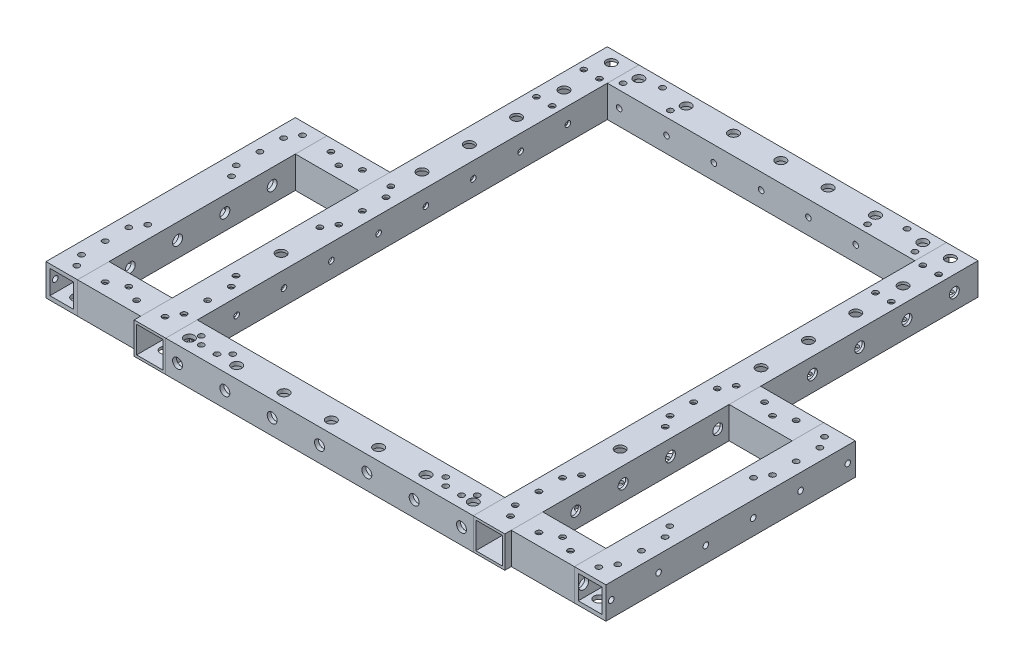
from build123d import *

# Parameters (mm, degrees)
BOSS_EXTRUDE1_DEPTH        = 105.6
BOSS_EXTRUDE1_DEPTH_BACK   = 275.4
SKETCH1_W                  = 25.4
SKETCH1_H                  = 25.4
SKETCH1_W_2                = 21.4
SKETCH1_H_2                = 21.4
BOSS_EXTRUDE1_2_DEPTH      = 105.6
BOSS_EXTRUDE1_2_DEPTH_BACK = 275.4
SKETCH10_W                 = 25.4
SKETCH10_H                 = 25.4
SKETCH10_W_2               = 19.05
SKETCH10_H_2               = 19.05
BOSS_EXTRUDE4_DEPTH        = 123.83
SKETCH5_W                  = 25.4
SKETCH5_H                  = 25.4
SKETCH5_W_2                = 21.4
SKETCH5_H_2                = 21.4
BOSS_EXTRUDE3_DEPTH        = 50.795
BOSS_EXTRUDE3_2_DEPTH      = 50.795
SKETCH11_W                 = 25.4
SKETCH11_H                 = 25.4
SKETCH11_W_2               = 19.05
SKETCH11_H_2               = 19.05
BOSS_EXTRUDE5_DEPTH        = 100.4
SKETCH12_R                 = 2.25
CUT_EXTRUDE1_DEPTH         = 10
SKETCH13_R                 = 4
CUT_EXTRUDE2_DEPTH         = 10
SKETCH14_R                 = 2.25
CUT_EXTRUDE3_DEPTH         = 10
SKETCH15_R                 = 4
CUT_EXTRUDE4_DEPTH         = 10
SKETCH17_R                 = 2.25
CUT_EXTRUDE5_DEPTH         = 10
SKETCH18_R                 = 4
CUT_EXTRUDE6_DEPTH         = 10
MIRROR6_COPY_1_SKETCH_R    = 2.25
MIRROR6_COPY_1_DEPTH       = 10
MIRROR6_COPY_2_SKETCH_R    = 4
MIRROR6_COPY_2_DEPTH       = 10
SKETCH19_R                 = 2.25
CUT_EXTRUDE7_DEPTH         = 10
SKETCH20_R                 = 4
CUT_EXTRUDE8_DEPTH         = 10
CUT_EXTRUDE9_START         = -10
SKETCH21_R                 = 2.25
CUT_EXTRUDE9_DEPTH         = 10
CUT_EXTRUDE10_START        = -10
SKETCH22_R                 = 4
CUT_EXTRUDE10_DEPTH        = 10
SKETCH23_R                 = 2.25
CUT_EXTRUDE11_DEPTH        = 10
SKETCH24_R                 = 4
CUT_EXTRUDE12_DEPTH        = 10
SKETCH25_R                 = 2.25
CUT_EXTRUDE13_DEPTH        = 10
SKETCH26_R                 = 4
CUT_EXTRUDE14_DEPTH        = 10
SKETCH27_R                 = 2.25
CUT_EXTRUDE20_DEPTH        = 10
SKETCH27_5_R               = 2.25
CUT_EXTRUDE21_DEPTH        = 10
SKETCH29_R                 = 4
CUT_EXTRUDE22_DEPTH        = 10
SKETCH29_3_R               = 4
CUT_EXTRUDE23_DEPTH        = 10
SKETCH31_R                 = 2.25
CUT_EXTRUDE25_DEPTH        = 10
SKETCH32_R                 = 2.25
CUT_EXTRUDE26_DEPTH        = 10


with BuildPart() as part:
    # Sketch1 → Boss-Extrude1 (new, two sides: drawn at the far end of the back side and taken through both)
    with BuildSketch(Plane.XY.offset(-BOSS_EXTRUDE1_DEPTH_BACK)):
        with Locations((-136.53, 0)):
            Rectangle(SKETCH1_W, SKETCH1_H)
        with Locations((-136.53, 0)):
            Rectangle(SKETCH1_W_2, SKETCH1_H_2, mode=Mode.SUBTRACT)
    extrude(amount=BOSS_EXTRUDE1_DEPTH + BOSS_EXTRUDE1_DEPTH_BACK)


with BuildPart() as body_2:
    # Sketch1 → Boss-Extrude1 2 (new, two sides: drawn at the far end of the back side and taken through both)
    with BuildSketch(Plane.XY.offset(-BOSS_EXTRUDE1_2_DEPTH_BACK)):
        with Locations((136.53, 0)):
            Rectangle(SKETCH1_W, SKETCH1_H)
        with Locations((136.53, 0)):
            Rectangle(SKETCH1_W_2, SKETCH1_H_2, mode=Mode.SUBTRACT)
    extrude(amount=BOSS_EXTRUDE1_2_DEPTH + BOSS_EXTRUDE1_2_DEPTH_BACK)


with BuildPart() as body_3:
    # Sketch10 → Boss-Extrude4 (new, symmetric)
    with BuildSketch(Plane(origin=(0, 0, 0), x_dir=(0, 0, -1), z_dir=(1, 0, 0))):
        with Locations((-92.9, 0)):
            Rectangle(SKETCH10_W, SKETCH10_H)
        with Locations((-92.9, 0)):
            Rectangle(SKETCH10_W_2, SKETCH10_H_2, mode=Mode.SUBTRACT)
    extrude(amount=BOSS_EXTRUDE4_DEPTH, both=True)

    # Sketch14 → Cut-Extrude3 (cut)
    with BuildSketch(Plane.XZ.offset(12.7)):
        with Locations((-114.3, 96.075)):
            Circle(SKETCH14_R)
        with Locations((-76.2, 96.075)):
            Circle(SKETCH14_R)
        with Locations((-38.1, 96.075)):
            Circle(SKETCH14_R)
        with Locations((0, 96.075)):
            Circle(SKETCH14_R)
        with Locations((38.1, 96.075)):
            Circle(SKETCH14_R)
        with Locations((76.2, 96.075)):
            Circle(SKETCH14_R)
        with Locations((114.3, 96.075)):
            Circle(SKETCH14_R)
    extrude(amount=-CUT_EXTRUDE3_DEPTH, mode=Mode.SUBTRACT)

    # Sketch15 → Cut-Extrude4 (cut)
    with BuildSketch(Plane(origin=(0, 12.7, 0), x_dir=(1, 0, 0), z_dir=(0, 1, 0))):
        with Locations((114.3, -96.075)):
            Circle(SKETCH15_R)
        with Locations((76.2, -96.075)):
            Circle(SKETCH15_R)
        with Locations((38.1, -96.075)):
            Circle(SKETCH15_R)
        with Locations((0, -96.075)):
            Circle(SKETCH15_R)
        with Locations((-38.1, -96.075)):
            Circle(SKETCH15_R)
        with Locations((-76.2, -96.075)):
            Circle(SKETCH15_R)
        with Locations((-114.3, -96.075)):
            Circle(SKETCH15_R)
    extrude(amount=-CUT_EXTRUDE4_DEPTH, mode=Mode.SUBTRACT)


with BuildPart() as body_4:
    # Sketch5 → Boss-Extrude3 (new body)
    with BuildSketch(Plane.ZY.offset(149.23)):
        with Locations((-87.7, 0)):
            Rectangle(SKETCH5_W, SKETCH5_H)
        with Locations((-87.7, 0)):
            Rectangle(SKETCH5_W_2, SKETCH5_H_2, mode=Mode.SUBTRACT)
    extrude(amount=BOSS_EXTRUDE3_DEPTH)


with BuildPart() as body_5:
    # Sketch5 → Boss-Extrude3 2 (new body)
    with BuildSketch(Plane.ZY.offset(149.23)):
        with Locations((87.7, 0)):
            Rectangle(SKETCH5_W, SKETCH5_H)
        with Locations((87.7, 0)):
            Rectangle(SKETCH5_W_2, SKETCH5_H_2, mode=Mode.SUBTRACT)
    extrude(amount=BOSS_EXTRUDE3_2_DEPTH)


with BuildPart() as body_6:
    # Sketch11 → Boss-Extrude5 (new, symmetric)
    with BuildSketch(Plane.XY):
        with Locations((-212.725, 0)):
            Rectangle(SKETCH11_W, SKETCH11_H)
        with Locations((-212.725, 0)):
            Rectangle(SKETCH11_W_2, SKETCH11_H_2, mode=Mode.SUBTRACT)
    extrude(amount=BOSS_EXTRUDE5_DEPTH, both=True)

    # Sketch12 → Cut-Extrude1 (cut)
    with BuildSketch(Plane.ZY.offset(225.425)):
        with Locations((-94.42, 0)):
            Circle(SKETCH12_R)
        with Locations((-56.32, 0)):
            Circle(SKETCH12_R)
        with Locations((-18.22, 0)):
            Circle(SKETCH12_R)
        with Locations((19.88, 0)):
            Circle(SKETCH12_R)
        with Locations((57.98, 0)):
            Circle(SKETCH12_R)
        with Locations((96.08, 0)):
            Circle(SKETCH12_R)
    extrude(amount=-CUT_EXTRUDE1_DEPTH, mode=Mode.SUBTRACT)

    # Sketch13 → Cut-Extrude2 (cut)
    with BuildSketch(Plane(origin=(-200.025, 0, 0), x_dir=(0, 0, -1), z_dir=(1, 0, 0))):
        with Locations((94.42, 0)):
            Circle(SKETCH13_R)
        with Locations((56.32, 0)):
            Circle(SKETCH13_R)
        with Locations((18.22, 0)):
            Circle(SKETCH13_R)
        with Locations((-19.88, 0)):
            Circle(SKETCH13_R)
        with Locations((-57.98, 0)):
            Circle(SKETCH13_R)
        with Locations((-96.08, 0)):
            Circle(SKETCH13_R)
    extrude(amount=-CUT_EXTRUDE2_DEPTH, mode=Mode.SUBTRACT)


with BuildPart() as body_7:
    # Mirror1: mirrored copy
    add(body_6.part.mirror(Plane(origin=(0, 0, 0), x_dir=(0, 0, 1), z_dir=(1, 0, 0))))


with BuildPart() as body_8:
    # Mirror1 2: mirrored copy
    add(body_5.part.mirror(Plane(origin=(0, 0, 0), x_dir=(0, 0, 1), z_dir=(1, 0, 0))))


with BuildPart() as body_9:
    # Mirror1 3: mirrored copy
    add(body_4.part.mirror(Plane(origin=(0, 0, 0), x_dir=(0, 0, 1), z_dir=(1, 0, 0))))


with BuildPart() as body_10:
    # Mirror3: mirrored copy
    add(body_3.part.mirror(Plane.XY.offset(-84.9)))

    # Sketch23 → Cut-Extrude11 (cut)
    with BuildSketch(Plane.XY.offset(-250)):
        with Locations((-114.3, 0)):
            Circle(SKETCH23_R)
        with Locations((-76.2, 0)):
            Circle(SKETCH23_R)
        with Locations((-38.1, 0)):
            Circle(SKETCH23_R)
        Circle(SKETCH23_R)
        with Locations((38.1, 0)):
            Circle(SKETCH23_R)
        with Locations((76.2, 0)):
            Circle(SKETCH23_R)
        with Locations((114.3, 0)):
            Circle(SKETCH23_R)
    extrude(amount=-CUT_EXTRUDE11_DEPTH, mode=Mode.SUBTRACT)

    # Sketch24 → Cut-Extrude12 (cut)
    with BuildSketch(Plane(origin=(0, 0, -275.4), x_dir=(-1, 0, 0), z_dir=(0, 0, -1))):
        with Locations((114.3, 0)):
            Circle(SKETCH24_R)
        with Locations((76.2, 0)):
            Circle(SKETCH24_R)
        with Locations((38.1, 0)):
            Circle(SKETCH24_R)
        Circle(SKETCH24_R)
        with Locations((-38.1, 0)):
            Circle(SKETCH24_R)
        with Locations((-76.2, 0)):
            Circle(SKETCH24_R)
        with Locations((-114.3, 0)):
            Circle(SKETCH24_R)
    extrude(amount=-CUT_EXTRUDE12_DEPTH, mode=Mode.SUBTRACT)


with BuildPart() as cut_extrude5_tool:
    # Sketch17 → Cut-Extrude5 (new body)
    with BuildSketch(Plane(origin=(0, 12.7, 0), x_dir=(1, 0, 0), z_dir=(0, 1, 0))):
        with Locations((139.065, -90.875)):
            Circle(SKETCH17_R)
        with Locations((133.35, -81.35)):
            Circle(SKETCH17_R)
        with Locations((161.925, -90.875)):
            Circle(SKETCH17_R)
        with Locations((133.35, -62.3)):
            Circle(SKETCH17_R)
        with Locations((187.325, -90.875)):
            Circle(SKETCH17_R)
        with Locations((210.185, -90.875)):
            Circle(SKETCH17_R)
        with Locations((215.9, -81.35)):
            Circle(SKETCH17_R)
        with Locations((215.9, -62.3)):
            Circle(SKETCH17_R)
        with Locations((215.9, -43.25)):
            Circle(SKETCH17_R)
        with Locations((210.185, -33.725)):
            Circle(SKETCH17_R)
        with Locations((139.065, -33.725)):
            Circle(SKETCH17_R)
        with Locations((133.35, -43.25)):
            Circle(SKETCH17_R)
        with Locations((174.625, -84.53)):
            Circle(SKETCH17_R)
    cut_extrude5 = extrude(amount=-CUT_EXTRUDE5_DEPTH)


with BuildPart() as body_2_1:
    add(body_2.part)

    # Cut-Extrude5: cut by cut_extrude5_tool
    add(cut_extrude5_tool.part, mode=Mode.SUBTRACT)


with BuildPart() as body_7_1:
    add(body_7.part)

    # Cut-Extrude5: cut by cut_extrude5_tool
    add(cut_extrude5_tool.part, mode=Mode.SUBTRACT)


with BuildPart() as body_8_1:
    add(body_8.part)

    # Cut-Extrude5: cut by cut_extrude5_tool
    add(cut_extrude5_tool.part, mode=Mode.SUBTRACT)


with BuildPart() as cut_extrude6_tool:
    # Sketch18 → Cut-Extrude6 (new body)
    with BuildSketch(Plane.XZ.offset(12.7)):
        with Locations((139.065, 90.875)):
            Circle(SKETCH18_R)
        with Locations((133.35, 81.35)):
            Circle(SKETCH18_R)
        with Locations((133.35, 62.3)):
            Circle(SKETCH18_R)
        with Locations((161.925, 90.875)):
            Circle(SKETCH18_R)
        with Locations((215.905, 62.3)):
            Circle(SKETCH18_R)
        with Locations((215.905, 81.35)):
            Circle(SKETCH18_R)
        with Locations((210.19, 90.875)):
            Circle(SKETCH18_R)
        with Locations((187.33, 90.875)):
            Circle(SKETCH18_R)
        with Locations((133.35, 43.25)):
            Circle(SKETCH18_R)
        with Locations((139.065, 33.725)):
            Circle(SKETCH18_R)
        with Locations((210.19, 33.725)):
            Circle(SKETCH18_R)
        with Locations((215.905, 43.25)):
            Circle(SKETCH18_R)
        with Locations((174.625, 84.53)):
            Circle(SKETCH18_R)
    cut_extrude6 = extrude(amount=-CUT_EXTRUDE6_DEPTH)


with BuildPart() as body_2_2:
    add(body_2_1.part)

    # Cut-Extrude6: cut by cut_extrude6_tool
    add(cut_extrude6_tool.part, mode=Mode.SUBTRACT)


with BuildPart() as body_7_2:
    add(body_7_1.part)

    # Cut-Extrude6: cut by cut_extrude6_tool
    add(cut_extrude6_tool.part, mode=Mode.SUBTRACT)


with BuildPart() as body_8_2:
    add(body_8_1.part)

    # Cut-Extrude6: cut by cut_extrude6_tool
    add(cut_extrude6_tool.part, mode=Mode.SUBTRACT)


with BuildPart() as mirror5_tool:
    # Mirror5: Cut-Extrude5, Cut-Extrude6 across plane
    add(cut_extrude5.mirror(Plane.XY))
    add(cut_extrude6.mirror(Plane.XY))


with BuildPart() as body_2_3:
    add(body_2_2.part)

    # Mirror5: cut by mirror5_tool
    add(mirror5_tool.part, mode=Mode.SUBTRACT)

    # Sketch21 → Cut-Extrude9 (cut)
    with BuildSketch(Plane.ZY.offset(-123.83).offset(CUT_EXTRUDE9_START)):
        with Locations((-256.35, 0)):
            Circle(SKETCH21_R)
        with Locations((-218.25, 0)):
            Circle(SKETCH21_R)
        with Locations((-180.15, 0)):
            Circle(SKETCH21_R)
        with Locations((-142.05, 0)):
            Circle(SKETCH21_R)
        with Locations((-103.95, 0)):
            Circle(SKETCH21_R)
        with Locations((-65.85, 0)):
            Circle(SKETCH21_R)
        with Locations((-27.75, 0)):
            Circle(SKETCH21_R)
        with Locations((10.35, 0)):
            Circle(SKETCH21_R)
        with Locations((48.45, 0)):
            Circle(SKETCH21_R)
        with Locations((86.55, 0)):
            Circle(SKETCH21_R)
    extrude(amount=CUT_EXTRUDE9_DEPTH, mode=Mode.SUBTRACT)

    # Sketch22 → Cut-Extrude10 (cut)
    with BuildSketch(Plane(origin=(149.23, 0, 0), x_dir=(0, 0, -1), z_dir=(1, 0, 0)).offset(CUT_EXTRUDE10_START)):
        with Locations((-86.55, 0)):
            Circle(SKETCH22_R)
        with Locations((-48.45, 0)):
            Circle(SKETCH22_R)
        with Locations((-10.35, 0)):
            Circle(SKETCH22_R)
        with Locations((27.75, 0)):
            Circle(SKETCH22_R)
        with Locations((65.85, 0)):
            Circle(SKETCH22_R)
        with Locations((103.95, 0)):
            Circle(SKETCH22_R)
        with Locations((142.05, 0)):
            Circle(SKETCH22_R)
        with Locations((180.15, 0)):
            Circle(SKETCH22_R)
        with Locations((218.25, 0)):
            Circle(SKETCH22_R)
        with Locations((256.35, 0)):
            Circle(SKETCH22_R)
    extrude(amount=CUT_EXTRUDE10_DEPTH, mode=Mode.SUBTRACT)


with BuildPart() as body_7_3:
    add(body_7_2.part)

    # Mirror5: cut by mirror5_tool
    add(mirror5_tool.part, mode=Mode.SUBTRACT)


with BuildPart() as body_9_1:
    add(body_9.part)

    # Mirror5: cut by mirror5_tool
    add(mirror5_tool.part, mode=Mode.SUBTRACT)


with BuildPart() as mirror6_tool:
    # Mirror6: Cut-Extrude5, Cut-Extrude6 across plane
    add(cut_extrude5.mirror(Plane(origin=(0, 0, 0), x_dir=(0, 0, 1), z_dir=(1, 0, 0))))
    add(cut_extrude6.mirror(Plane(origin=(0, 0, 0), x_dir=(0, 0, 1), z_dir=(1, 0, 0))))


with BuildPart() as part_1:
    add(part.part)

    # Mirror6: cut by mirror6_tool
    add(mirror6_tool.part, mode=Mode.SUBTRACT)


with BuildPart() as body_5_1:
    add(body_5.part)

    # Mirror6: cut by mirror6_tool
    add(mirror6_tool.part, mode=Mode.SUBTRACT)


with BuildPart() as body_6_1:
    add(body_6.part)

    # Mirror6: cut by mirror6_tool
    add(mirror6_tool.part, mode=Mode.SUBTRACT)


with BuildPart() as mirror6_copy_1_tool:
    # Mirror6 copy 1 sketch → Mirror6 copy 1 (new body)
    with BuildSketch(Plane(origin=(0, 12.7, 0), x_dir=(-1, 0, 0), z_dir=(0, 1, 0))):
        with Locations((139.065, -90.875)):
            Circle(MIRROR6_COPY_1_SKETCH_R)
        with Locations((133.35, -81.35)):
            Circle(MIRROR6_COPY_1_SKETCH_R)
        with Locations((161.925, -90.875)):
            Circle(MIRROR6_COPY_1_SKETCH_R)
        with Locations((133.35, -62.3)):
            Circle(MIRROR6_COPY_1_SKETCH_R)
        with Locations((187.325, -90.875)):
            Circle(MIRROR6_COPY_1_SKETCH_R)
        with Locations((210.185, -90.875)):
            Circle(MIRROR6_COPY_1_SKETCH_R)
        with Locations((215.9, -81.35)):
            Circle(MIRROR6_COPY_1_SKETCH_R)
        with Locations((215.9, -62.3)):
            Circle(MIRROR6_COPY_1_SKETCH_R)
        with Locations((215.9, -43.25)):
            Circle(MIRROR6_COPY_1_SKETCH_R)
        with Locations((210.185, -33.725)):
            Circle(MIRROR6_COPY_1_SKETCH_R)
        with Locations((139.065, -33.725)):
            Circle(MIRROR6_COPY_1_SKETCH_R)
        with Locations((133.35, -43.25)):
            Circle(MIRROR6_COPY_1_SKETCH_R)
        with Locations((174.625, -84.53)):
            Circle(MIRROR6_COPY_1_SKETCH_R)
    extrude(amount=-MIRROR6_COPY_1_DEPTH)


with BuildPart() as part_2:
    add(part_1.part)

    # Mirror6 copy 1: cut by mirror6_copy_1_tool
    add(mirror6_copy_1_tool.part, mode=Mode.SUBTRACT)


with BuildPart() as body_4_1:
    add(body_4.part)

    # Mirror6 copy 1: cut by mirror6_copy_1_tool
    add(mirror6_copy_1_tool.part, mode=Mode.SUBTRACT)


with BuildPart() as body_6_2:
    add(body_6_1.part)

    # Mirror6 copy 1: cut by mirror6_copy_1_tool
    add(mirror6_copy_1_tool.part, mode=Mode.SUBTRACT)


with BuildPart() as mirror6_copy_2_tool:
    # Mirror6 copy 2 sketch → Mirror6 copy 2 (new body)
    with BuildSketch(Plane(origin=(0, -12.7, 0), x_dir=(-1, 0, 0), z_dir=(0, -1, 0))):
        with Locations((139.065, 90.875)):
            Circle(MIRROR6_COPY_2_SKETCH_R)
        with Locations((133.35, 81.35)):
            Circle(MIRROR6_COPY_2_SKETCH_R)
        with Locations((133.35, 62.3)):
            Circle(MIRROR6_COPY_2_SKETCH_R)
        with Locations((161.925, 90.875)):
            Circle(MIRROR6_COPY_2_SKETCH_R)
        with Locations((215.905, 62.3)):
            Circle(MIRROR6_COPY_2_SKETCH_R)
        with Locations((215.905, 81.35)):
            Circle(MIRROR6_COPY_2_SKETCH_R)
        with Locations((210.19, 90.875)):
            Circle(MIRROR6_COPY_2_SKETCH_R)
        with Locations((187.33, 90.875)):
            Circle(MIRROR6_COPY_2_SKETCH_R)
        with Locations((133.35, 43.25)):
            Circle(MIRROR6_COPY_2_SKETCH_R)
        with Locations((139.065, 33.725)):
            Circle(MIRROR6_COPY_2_SKETCH_R)
        with Locations((210.19, 33.725)):
            Circle(MIRROR6_COPY_2_SKETCH_R)
        with Locations((215.905, 43.25)):
            Circle(MIRROR6_COPY_2_SKETCH_R)
        with Locations((174.625, 84.53)):
            Circle(MIRROR6_COPY_2_SKETCH_R)
    extrude(amount=-MIRROR6_COPY_2_DEPTH)


with BuildPart() as part_3:
    add(part_2.part)

    # Mirror6 copy 2: cut by mirror6_copy_2_tool
    add(mirror6_copy_2_tool.part, mode=Mode.SUBTRACT)

    # Sketch19 → Cut-Extrude7 (cut)
    with BuildSketch(Plane(origin=(-123.83, 0, 0), x_dir=(0, 0, -1), z_dir=(1, 0, 0))):
        with Locations((-86.55, 0)):
            Circle(SKETCH19_R)
        with Locations((-48.45, 0)):
            Circle(SKETCH19_R)
        with Locations((-10.35, 0)):
            Circle(SKETCH19_R)
        with Locations((27.75, 0)):
            Circle(SKETCH19_R)
        with Locations((65.85, 0)):
            Circle(SKETCH19_R)
        with Locations((103.95, 0)):
            Circle(SKETCH19_R)
        with Locations((142.05, 0)):
            Circle(SKETCH19_R)
        with Locations((180.15, 0)):
            Circle(SKETCH19_R)
        with Locations((218.25, 0)):
            Circle(SKETCH19_R)
        with Locations((256.35, 0)):
            Circle(SKETCH19_R)
    extrude(amount=-CUT_EXTRUDE7_DEPTH, mode=Mode.SUBTRACT)

    # Sketch20 → Cut-Extrude8 (cut)
    with BuildSketch(Plane.ZY.offset(149.23)):
        with Locations((86.55, 0)):
            Circle(SKETCH20_R)
        with Locations((48.45, 0)):
            Circle(SKETCH20_R)
        with Locations((10.35, 0)):
            Circle(SKETCH20_R)
        with Locations((-27.75, 0)):
            Circle(SKETCH20_R)
        with Locations((-65.85, 0)):
            Circle(SKETCH20_R)
        with Locations((-103.95, 0)):
            Circle(SKETCH20_R)
        with Locations((-142.05, 0)):
            Circle(SKETCH20_R)
        with Locations((-180.15, 0)):
            Circle(SKETCH20_R)
        with Locations((-218.25, 0)):
            Circle(SKETCH20_R)
        with Locations((-256.35, 0)):
            Circle(SKETCH20_R)
    extrude(amount=-CUT_EXTRUDE8_DEPTH, mode=Mode.SUBTRACT)


with BuildPart() as body_4_2:
    add(body_4_1.part)

    # Mirror6 copy 2: cut by mirror6_copy_2_tool
    add(mirror6_copy_2_tool.part, mode=Mode.SUBTRACT)


with BuildPart() as body_6_3:
    add(body_6_2.part)

    # Mirror6 copy 2: cut by mirror6_copy_2_tool
    add(mirror6_copy_2_tool.part, mode=Mode.SUBTRACT)


with BuildPart() as body_3_1:
    add(body_3.part)

    # Sketch25 → Cut-Extrude13 (cut)
    with BuildSketch(Plane(origin=(0, 0, 80.2), x_dir=(-1, 0, 0), z_dir=(0, 0, -1))):
        with Locations((114.3, 0)):
            Circle(SKETCH25_R)
        with Locations((76.2, 0)):
            Circle(SKETCH25_R)
        with Locations((38.1, 0)):
            Circle(SKETCH25_R)
        Circle(SKETCH25_R)
        with Locations((-38.1, 0)):
            Circle(SKETCH25_R)
        with Locations((-76.2, 0)):
            Circle(SKETCH25_R)
        with Locations((-114.3, 0)):
            Circle(SKETCH25_R)
    extrude(amount=-CUT_EXTRUDE13_DEPTH, mode=Mode.SUBTRACT)

    # Sketch26 → Cut-Extrude14 (cut)
    with BuildSketch(Plane.XY.offset(105.6)):
        with Locations((-114.3, 0)):
            Circle(SKETCH26_R)
        with Locations((-76.2, 0)):
            Circle(SKETCH26_R)
        with Locations((-38.1, 0)):
            Circle(SKETCH26_R)
        Circle(SKETCH26_R)
        with Locations((38.1, 0)):
            Circle(SKETCH26_R)
        with Locations((76.2, 0)):
            Circle(SKETCH26_R)
        with Locations((114.3, 0)):
            Circle(SKETCH26_R)
    extrude(amount=-CUT_EXTRUDE14_DEPTH, mode=Mode.SUBTRACT)

    # Sketch32 → Cut-Extrude26 (cut)
    with BuildSketch(Plane(origin=(0, 12.7, 0), x_dir=(1, 0, 0), z_dir=(0, 1, 0))):
        with Locations((111.125, -89.725)):
            Circle(SKETCH32_R)
        with Locations((104.775, -96.07)):
            Circle(SKETCH32_R)
        with Locations((92.075, -96.07)):
            Circle(SKETCH32_R)
        with Locations((85.725, -89.725)):
            Circle(SKETCH32_R)
        with Locations((-85.725, -89.725)):
            Circle(SKETCH32_R)
        with Locations((-92.075, -96.07)):
            Circle(SKETCH32_R)
        with Locations((-104.775, -96.07)):
            Circle(SKETCH32_R)
        with Locations((-111.125, -89.725)):
            Circle(SKETCH32_R)
    extrude(amount=-CUT_EXTRUDE26_DEPTH, mode=Mode.SUBTRACT)


with BuildPart() as cut_extrude20_tool:
    # Sketch27 → Cut-Extrude20 (new body)
    with BuildSketch(Plane.XZ.offset(12.7)):
        with Locations((136.53, 0)):
            Circle(SKETCH27_R)
        with Locations((-136.53, 0)):
            Circle(SKETCH27_R)
    extrude(amount=-CUT_EXTRUDE20_DEPTH)


with BuildPart() as part_4:
    add(part_3.part)

    # Cut-Extrude20: cut by cut_extrude20_tool
    add(cut_extrude20_tool.part, mode=Mode.SUBTRACT)


with BuildPart() as body_2_4:
    add(body_2_3.part)

    # Cut-Extrude20: cut by cut_extrude20_tool
    add(cut_extrude20_tool.part, mode=Mode.SUBTRACT)


with BuildPart() as cut_extrude21_tool:
    # Sketch27_5 → Cut-Extrude21 (new body)
    with BuildSketch(Plane.XZ.offset(12.7)):
        with Locations((136.53, -113.47)):
            Circle(SKETCH27_5_R)
        with Locations((136.53, -151.57)):
            Circle(SKETCH27_5_R)
        with Locations((136.53, -189.67)):
            Circle(SKETCH27_5_R)
        with Locations((136.53, -227.77)):
            Circle(SKETCH27_5_R)
        with Locations((-136.53, -113.47)):
            Circle(SKETCH27_5_R)
        with Locations((-136.53, -151.57)):
            Circle(SKETCH27_5_R)
        with Locations((-136.53, -189.67)):
            Circle(SKETCH27_5_R)
        with Locations((-136.53, -227.77)):
            Circle(SKETCH27_5_R)
        with Locations((136.53, -265.87)):
            Circle(SKETCH27_5_R)
        with Locations((-136.53, -265.87)):
            Circle(SKETCH27_5_R)
    extrude(amount=-CUT_EXTRUDE21_DEPTH)


with BuildPart() as part_5:
    add(part_4.part)

    # Cut-Extrude21: cut by cut_extrude21_tool
    add(cut_extrude21_tool.part, mode=Mode.SUBTRACT)


with BuildPart() as body_2_5:
    add(body_2_4.part)

    # Cut-Extrude21: cut by cut_extrude21_tool
    add(cut_extrude21_tool.part, mode=Mode.SUBTRACT)


with BuildPart() as cut_extrude22_tool:
    # Sketch29 → Cut-Extrude22 (new body)
    with BuildSketch(Plane(origin=(0, 12.7, 0), x_dir=(1, 0, 0), z_dir=(0, 1, 0))):
        with Locations((136.53, 0)):
            Circle(SKETCH29_R)
        with Locations((-136.53, 0)):
            Circle(SKETCH29_R)
    extrude(amount=-CUT_EXTRUDE22_DEPTH)


with BuildPart() as part_6:
    add(part_5.part)

    # Cut-Extrude22: cut by cut_extrude22_tool
    add(cut_extrude22_tool.part, mode=Mode.SUBTRACT)


with BuildPart() as body_2_6:
    add(body_2_5.part)

    # Cut-Extrude22: cut by cut_extrude22_tool
    add(cut_extrude22_tool.part, mode=Mode.SUBTRACT)


with BuildPart() as cut_extrude23_tool:
    # Sketch29_3 → Cut-Extrude23 (new body)
    with BuildSketch(Plane(origin=(0, 12.7, 0), x_dir=(1, 0, 0), z_dir=(0, 1, 0))):
        with Locations((136.53, 113.47)):
            Circle(SKETCH29_3_R)
        with Locations((136.53, 151.57)):
            Circle(SKETCH29_3_R)
        with Locations((136.53, 189.67)):
            Circle(SKETCH29_3_R)
        with Locations((136.53, 227.77)):
            Circle(SKETCH29_3_R)
        with Locations((-136.53, 227.77)):
            Circle(SKETCH29_3_R)
        with Locations((-136.53, 189.67)):
            Circle(SKETCH29_3_R)
        with Locations((-136.53, 151.57)):
            Circle(SKETCH29_3_R)
        with Locations((-136.53, 113.47)):
            Circle(SKETCH29_3_R)
        with Locations((-136.53, 265.87)):
            Circle(SKETCH29_3_R)
        with Locations((136.53, 265.87)):
            Circle(SKETCH29_3_R)
    extrude(amount=-CUT_EXTRUDE23_DEPTH)


with BuildPart() as part_7:
    add(part_6.part)

    # Cut-Extrude23: cut by cut_extrude23_tool
    add(cut_extrude23_tool.part, mode=Mode.SUBTRACT)


with BuildPart() as body_2_7:
    add(body_2_6.part)

    # Cut-Extrude23: cut by cut_extrude23_tool
    add(cut_extrude23_tool.part, mode=Mode.SUBTRACT)


with BuildPart() as cut_extrude25_tool:
    # Sketch31 → Cut-Extrude25 (new body)
    with BuildSketch(Plane(origin=(0, 12.7, 0), x_dir=(1, 0, 0), z_dir=(0, 1, 0))):
        with Locations((130.18, 250)):
            Circle(SKETCH31_R)
        with Locations((142.88, 250)):
            Circle(SKETCH31_R)
        with Locations((130.18, 211.9)):
            Circle(SKETCH31_R)
        with Locations((142.88, 211.9)):
            Circle(SKETCH31_R)
        with Locations((79.38, 256.35)):
            Circle(SKETCH31_R)
        with Locations((117.48, 256.35)):
            Circle(SKETCH31_R)
        with Locations((98.43, 269.05)):
            Circle(SKETCH31_R)
        with Locations((-142.88, 211.9)):
            Circle(SKETCH31_R)
        with Locations((-130.18, 211.9)):
            Circle(SKETCH31_R)
        with Locations((-130.18, 250)):
            Circle(SKETCH31_R)
        with Locations((-142.88, 250)):
            Circle(SKETCH31_R)
        with Locations((-117.48, 256.35)):
            Circle(SKETCH31_R)
        with Locations((-98.43, 269.05)):
            Circle(SKETCH31_R)
        with Locations((-79.38, 256.35)):
            Circle(SKETCH31_R)
    extrude(amount=-CUT_EXTRUDE25_DEPTH)


with BuildPart() as part_8:
    add(part_7.part)

    # Cut-Extrude25: cut by cut_extrude25_tool
    add(cut_extrude25_tool.part, mode=Mode.SUBTRACT)


with BuildPart() as body_2_8:
    add(body_2_7.part)

    # Cut-Extrude25: cut by cut_extrude25_tool
    add(cut_extrude25_tool.part, mode=Mode.SUBTRACT)


with BuildPart() as body_10_1:
    add(body_10.part)

    # Cut-Extrude25: cut by cut_extrude25_tool
    add(cut_extrude25_tool.part, mode=Mode.SUBTRACT)


solid = Compound([body_8_2.part, body_7_3.part, body_9_1.part, body_5_1.part, body_4_2.part, body_6_3.part, body_3_1.part, part_8.part, body_2_8.part, body_10_1.part])
